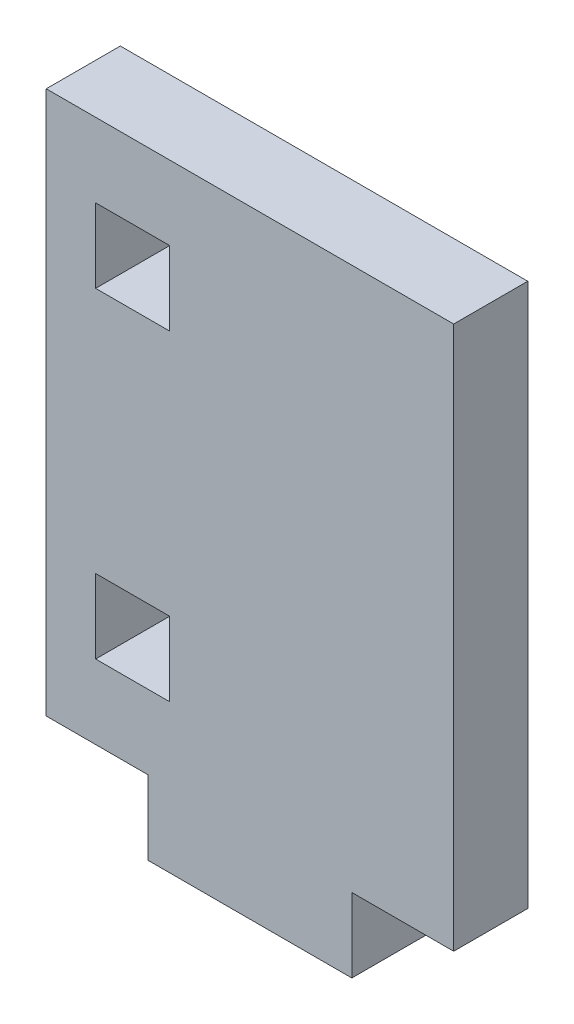
from build123d import *

# Parameters (mm, degrees)
SKETCH1_W           = 16.5
SKETCH1_H           = 22
BOSS_EXTRUDE1_DEPTH = 3
SKETCH2_W           = 8.25
SKETCH2_H           = 3
BOSS_EXTRUDE2_DEPTH = 3
SKETCH3_W           = 3
SKETCH3_H           = 3
CUT_EXTRUDE1_DEPTH  = 3


with BuildPart() as part:
    # Sketch1 → Boss-Extrude1 (new body)
    with BuildSketch(Plane.XY):
        Rectangle(SKETCH1_W, SKETCH1_H)
    extrude(amount=BOSS_EXTRUDE1_DEPTH)

    # Sketch2 → Boss-Extrude2 (add)
    with BuildSketch(Plane(origin=(0, -11, 0), x_dir=(-1, 0, 0), z_dir=(0, -1, 0))):
        with Locations((0, -1.5)):
            Rectangle(SKETCH2_W, SKETCH2_H)
    extrude(amount=BOSS_EXTRUDE2_DEPTH)

    # Sketch3 → Cut-Extrude1 (cut)
    with BuildSketch(Plane.XY.offset(3)):
        with Locations((-4.75, -6.5)):
            Rectangle(SKETCH3_W, SKETCH3_H)
        with Locations((-4.75, 6.5)):
            Rectangle(SKETCH3_W, SKETCH3_H)
    extrude(amount=-CUT_EXTRUDE1_DEPTH, mode=Mode.SUBTRACT)


solid = part.part
